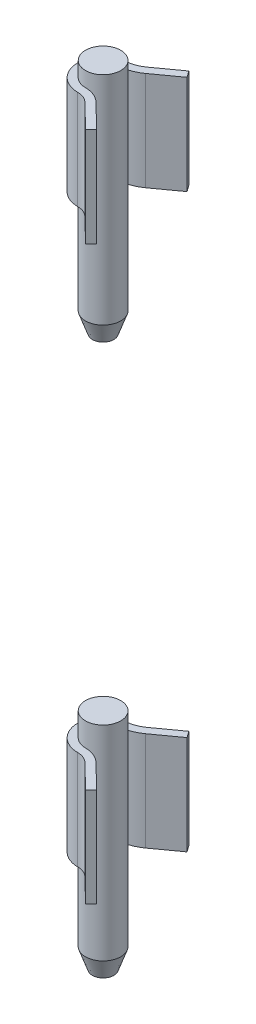
from build123d import *

# Parameters (mm, degrees)
SKETCH1_R           = 4.5
BOSS_EXTRUDE1_DEPTH = 55
CHAMFER1_SIZE       = 1.75
CHAMFER1_SIZE2      = 5
BOSS_EXTRUDE2_DEPTH = 25.3
LPATTERN1_COUNT     = 2
LPATTERN1_PITCH     = 146.1
SKETCH4_R           = 4.5
BOSS_EXTRUDE3_DEPTH = 2.2


with BuildPart() as part:
    # Sketch1 → Boss-Extrude1 (new body)
    with BuildSketch(Plane(origin=(0, 0, 0), x_dir=(1, 0, 0), z_dir=(0, 1, 0))):
        Circle(SKETCH1_R)
    extrude(amount=BOSS_EXTRUDE1_DEPTH)

    # Chamfer1
    chamfer1_edges = [part.edges().sort_by_distance(p)[0] for p in [
        (-4.5, 0, 0),
    ]]
    chamfer1_side = [part.faces().sort_by_distance(p)[0] for p in [
        (0, 0, 0),
    ]]
    chamfer(chamfer1_edges, length=CHAMFER1_SIZE, length2=CHAMFER1_SIZE2, reference=chamfer1_side[0])

    # Sketch2 → Boss-Extrude2 (add)
    with BuildSketch(Plane(origin=(0, 25.9, 0), x_dir=(-1, 0, 0), z_dir=(0, -1, 0))):
        with BuildLine():
            Line((-10.667941217, -12.326088827), (-4.5, -6.327398099))
            ThreePointArc((-4.5, -6.327398099), (-2.428445172, -4.974274671), (0, -4.5))
            ThreePointArc((0, -4.5), (4.495084869, -0.210266542), (0.420073756, 4.480350214))
            ThreePointArc((0.420073756, 4.480350214), (-2.163354244, 5.075191059), (-4.5, 6.327398099))
            Line((-4.5, 6.327398099), (-10.667941217, 10.775365439))
            Line((-10.667941217, 10.775365439), (-9.498111019, 12.397554486))
            Line((-9.498111019, 12.397554486), (-3.330169801, 7.949587147))
            ThreePointArc((-3.330169801, 7.949587147), (-1.460433366, 6.947596528), (0.606773203, 6.471616976))
            ThreePointArc((0.606773203, 6.471616976), (6.492900367, -0.303718338), (0, -6.5))
            ThreePointArc((0, -6.5), (-1.67594801, -6.827312183), (-3.105594531, -7.761146121))
            Line((-3.105594531, -7.761146121), (-9.273535749, -13.759836849))
            Line((-9.273535749, -13.759836849), (-10.667941217, -12.326088827))
        make_face()
    extrude(amount=-BOSS_EXTRUDE2_DEPTH)


with BuildPart() as lpattern1_1:
    # LPattern1: pattern copy
    add(part.part.moved(Location(Vector(0, 1, 0) * (1 * LPATTERN1_PITCH))))

    # Sketch3 → Revolve3 (revolve)
    with BuildSketch(Plane(origin=(0, 0, 0), x_dir=(0, 0, -1), z_dir=(1, 0, 0))):
        Polygon((0, 146.1), (0, 140.7), (-2.75, 140.7), (-4.5, 145.7), (-4.5, 151.1), (-2.75, 146.1), align=None)
    revolve(axis=Axis((0, 146.1, 0), (0, -1, 0)))


with BuildPart() as part_1:
    add(part.part)

    # Sketch4 → Boss-Extrude3 (add)
    with BuildSketch(Plane(origin=(0, 55, 0), x_dir=(1, 0, 0), z_dir=(0, 1, 0))):
        Circle(SKETCH4_R)
    extrude(amount=BOSS_EXTRUDE3_DEPTH)


solid = Compound([lpattern1_1.part, part_1.part])
